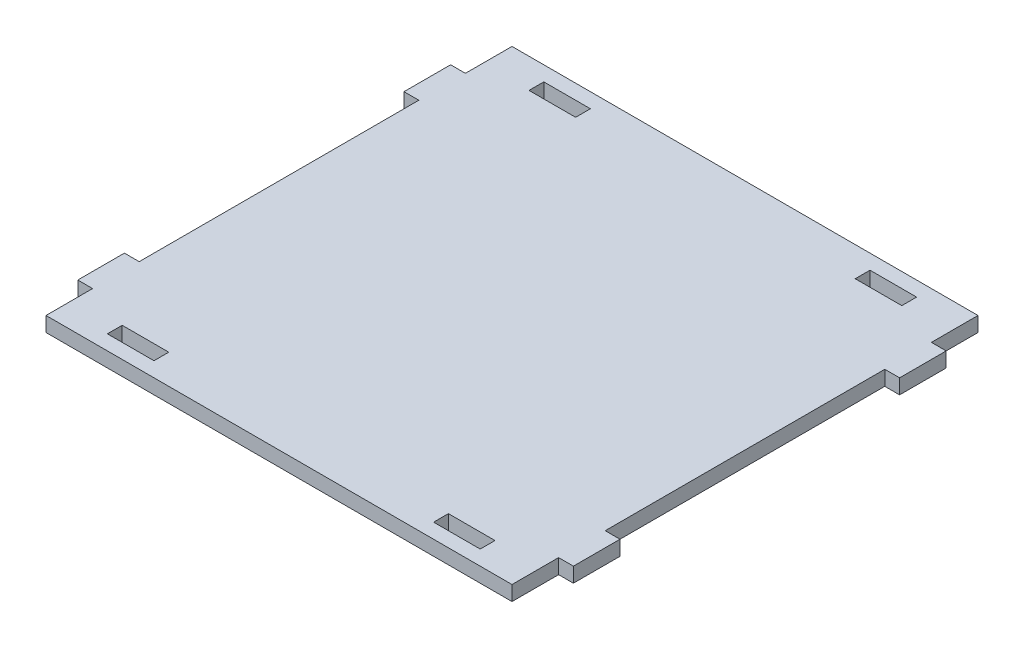
from build123d import *

# Parameters (mm, degrees)
SKETCH2_W           = 10
SKETCH2_H           = 3.175
BOSS_EXTRUDE1_DEPTH = 3.175


with BuildPart() as part:
    # Sketch2 → Boss-Extrude1 (new body)
    with BuildSketch(Plane(origin=(0, 0, 0), x_dir=(1, 0, 0), z_dir=(0, 1, 0))):
        Polygon((11.456556246, -72.927322323), (111.456556246, -72.927322323), (111.456556246, -62.927322323), (114.631556246, -62.927322323), (114.631556246, -52.927322323), (111.456556246, -52.927322323), (111.456556246, 7.072677677), (114.631556246, 7.072677677), (114.631556246, 17.072677677), (111.456556246, 17.072677677), (111.456556246, 27.072677677), (11.456556246, 27.072677677), (11.456556246, 17.072677677), (8.281556246, 17.072677677), (8.281556246, 7.072677677), (11.456556246, 7.072677677), (11.456556246, -52.927322323), (8.281556246, -52.927322323), (8.281556246, -62.927322323), (11.456556246, -62.927322323), align=None)
        with Locations((26.456556246, 22.310177677)):
            Rectangle(SKETCH2_W, SKETCH2_H, mode=Mode.SUBTRACT)
        with Locations((96.456556246, 22.310177677)):
            Rectangle(SKETCH2_W, SKETCH2_H, mode=Mode.SUBTRACT)
        with Locations((96.456556246, -68.164822323)):
            Rectangle(SKETCH2_W, SKETCH2_H, mode=Mode.SUBTRACT)
        with Locations((26.456556246, -68.164822323)):
            Rectangle(SKETCH2_W, SKETCH2_H, mode=Mode.SUBTRACT)
    extrude(amount=BOSS_EXTRUDE1_DEPTH)


solid = part.part
